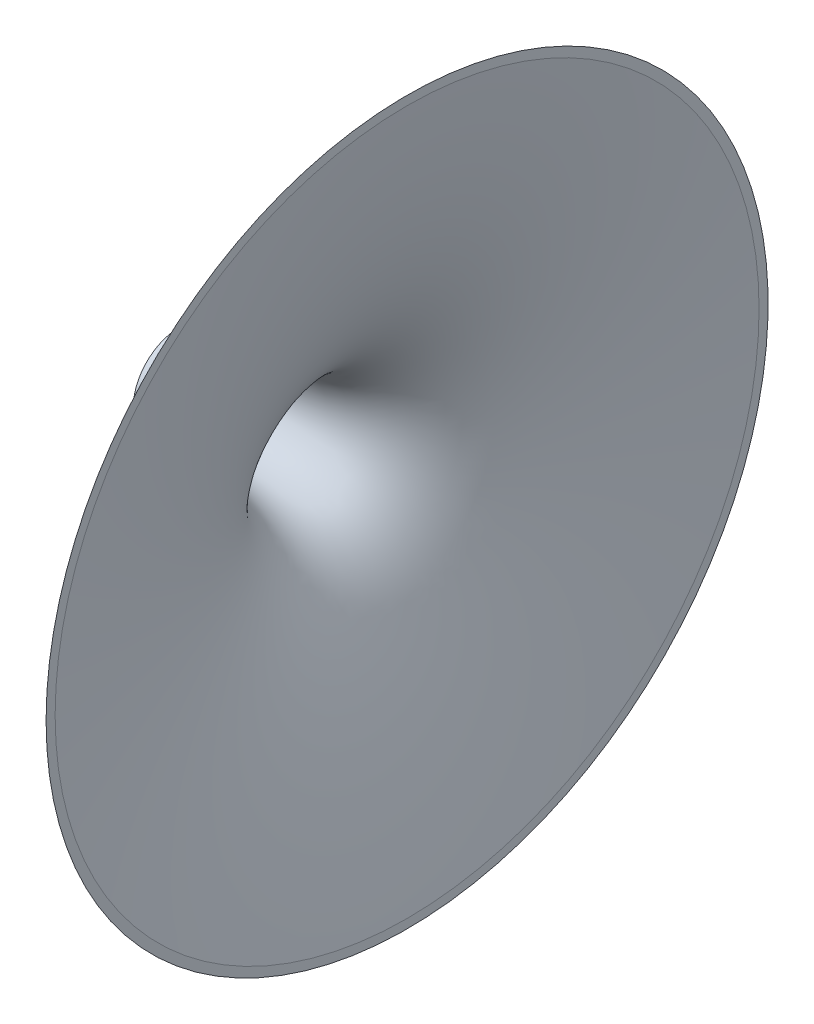
from build123d import *


with BuildPart() as part:
    # Sketch7 → Revolve1 (revolve)
    with BuildSketch(Plane.XY):
        with BuildLine():
            Line((0, 12.818309886), (0, 10.318309885))
            add(Edge.make_bspline(
                [(0, 10.318309885), (0.241417495, 10.32517476), (0.734433944, 10.339715811), (1.722937152, 10.37024976), (2.753961006, 10.406429018), (4.173796698, 10.460382124), (5.819490093, 10.532314215), (7.713041475, 10.629027344), (9.806560842, 10.759110102), (12.343965648, 10.948299111), (14.872149513, 11.18578719), (17.455534085, 11.494136809), (20.034775627, 11.891687062), (22.122919883, 12.280990003), (24.375936647, 12.785849507), (26.782186189, 13.444939122), (29.20394228, 14.275710799), (31.599374317, 15.310895211), (33.741692526, 16.444596155), (35.635821437, 17.637884373), (37.420714534, 18.963650188), (39.217056869, 20.522352313), (41.042853922, 22.37992281), (42.854842835, 24.55481762), (44.835264408, 27.359797639), (46.816401208, 30.714124754), (48.844467735, 34.818237912), (51.172970998, 40.499397041), (53.10911629, 46.340896677), (54.768438732, 52.262828847), (56.158600941, 57.953904573), (57.175152361, 62.527239728), (58.110791022, 67.120799293), (58.976277277, 71.722581309), (59.681909052, 75.767384908), (60.252098155, 79.225934732), (60.710122374, 82.133482088), (61.060203839, 84.42154378), (61.410020234, 86.79177214), (61.73138015, 89.019567857), (62.075101391, 91.496460827), (62.354424208, 93.542434665), (62.633670193, 95.670580979), (62.766983469, 96.698802786), (62.831853072, 97.204152676)],
                knots=[0.044481004, 0.044481004, 0.044481004, 0.044481004, 0.044481004, 0.052341452, 0.060201899, 0.068062346, 0.075922794, 0.091643688, 0.107364583, 0.121419833, 0.135475083, 0.163585582, 0.179306482, 0.195027382, 0.209363998, 0.223700613, 0.244661749, 0.265622904, 0.281777211, 0.297498302, 0.313218852, 0.328939633, 0.34466113, 0.364767853, 0.386877135, 0.408986526, 0.44177541, 0.474939447, 0.516363811, 0.582691628, 0.615855996, 0.649020363, 0.682184292, 0.715348221, 0.748512233, 0.781676244, 0.798258582, 0.814840919, 0.831423257, 0.848005594, 0.86458787, 0.881170146, 0.897752422, 0.914334697, 0.914334697, 0.914334697, 0.914334697, 0.914334697], degree=4))
            Line((62.831853072, 97.204152676), (62.831853072, 99.704152675))
            add(Edge.make_bspline(
                [(0, 12.818309886), (0.24141751, 12.825174762), (0.734433959, 12.839715812), (1.722937167, 12.870249762), (2.753961021, 12.90642902), (4.173796713, 12.960382125), (5.819490107, 13.032314217), (7.71304149, 13.129027346), (9.806560857, 13.259110104), (12.343965663, 13.448299114), (14.872149528, 13.685787193), (17.455534099, 13.994136812), (20.034775642, 14.391687065), (22.122919897, 14.780990007), (24.375936662, 15.285849511), (26.782186204, 15.944939127), (29.203942294, 16.775710803), (31.599374332, 17.810895216), (33.74169254, 18.94459616), (35.635821451, 20.137884379), (37.420714548, 21.463650194), (39.217056883, 23.022352319), (41.042853936, 24.879922816), (42.854842849, 27.054817626), (44.835264421, 29.859797646), (46.816401221, 33.214124761), (48.844467747, 37.318237919), (51.172971009, 42.999397048), (53.1091163, 48.840896684), (54.768438742, 54.762828854), (56.15860095, 60.45390458), (57.17515237, 65.027239736), (58.11079103, 69.6207993), (58.976277285, 74.222581317), (59.681909059, 78.267384916), (60.252098162, 81.72593474), (60.71012238, 84.633482096), (61.060203845, 86.921543789), (61.41002024, 89.291772149), (61.731380156, 91.519567866), (62.075101397, 93.996460835), (62.354424213, 96.042434673), (62.633670198, 98.170580987), (62.766983474, 99.198802793), (62.831853072, 99.704152675)],
                knots=[0.044481004, 0.044481004, 0.044481004, 0.044481004, 0.044481004, 0.052341452, 0.060201899, 0.068062346, 0.075922794, 0.091643688, 0.107364583, 0.121419833, 0.135475083, 0.163585582, 0.179306482, 0.195027382, 0.209363998, 0.223700613, 0.244661749, 0.265622904, 0.281777211, 0.297498302, 0.313218852, 0.328939633, 0.34466113, 0.364767853, 0.386877135, 0.408986526, 0.44177541, 0.474939447, 0.516363811, 0.582691628, 0.615855996, 0.649020363, 0.682184292, 0.715348221, 0.748512233, 0.781676244, 0.798258582, 0.814840919, 0.831423257, 0.848005594, 0.86458787, 0.881170146, 0.897752422, 0.914334697, 0.914334697, 0.914334697, 0.914334697, 0.914334697], degree=4))
        make_face()
    revolve(axis=Axis((0, 0, 0), (1, 0, 0)))


solid = part.part
